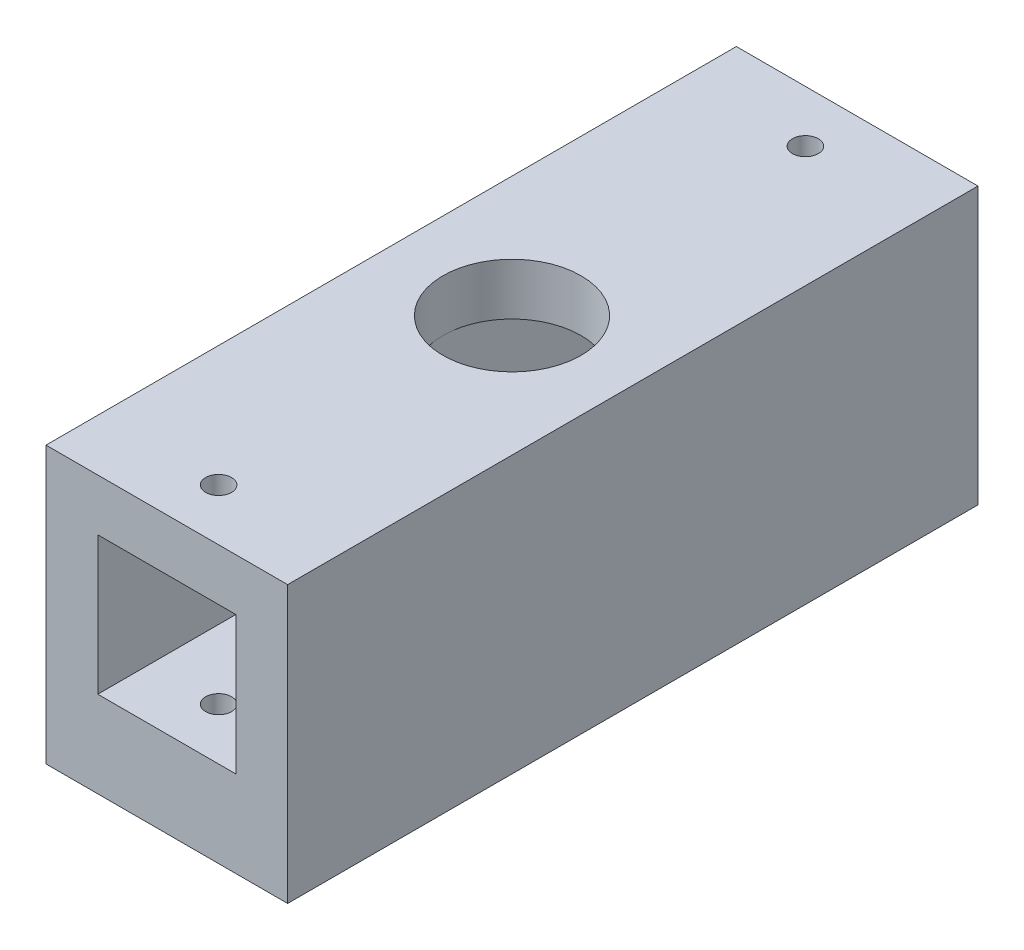
from build123d import *

# Parameters (mm, degrees)
SKETCH1_W               = 8
SKETCH1_H               = 8
BOSS_EXTRUDE1_DEPTH     = 40
SKETCH2_R               = 2.75
CUT_EXTRUDE1_DEPTH      = 18
SKETCH4_R               = 0.75
CUT_EXTRUDE2_DEPTH      = 19
CUT_EXTRUDE3_DEPTH      = 30
CUT_EXTRUDE3_DEPTH_BACK = 2
SKETCH2_5_R             = 4


with BuildPart() as part:
    # Sketch1 → Boss-Extrude1 (new body)
    with BuildSketch(Plane.XY):
        Polygon((-7, 7), (-7, -7), (-7, -9), (7, -9), (7, -7), (7, 7), align=None)
        Rectangle(SKETCH1_W, SKETCH1_H, mode=Mode.SUBTRACT)
    extrude(amount=BOSS_EXTRUDE1_DEPTH)

    # Sketch2 → Cut-Extrude1 (cut)
    with BuildSketch(Plane(origin=(0, -4, 0), x_dir=(1, 0, 0), z_dir=(0, 1, 0))):
        with Locations((0, -20)):
            Circle(SKETCH2_R)
    extrude(amount=-CUT_EXTRUDE1_DEPTH, mode=Mode.SUBTRACT)

    # Sketch4 → Cut-Extrude2 (cut)
    with BuildSketch(Plane(origin=(0, 7, 0), x_dir=(1, 0, 0), z_dir=(0, 1, 0))):
        with Locations((0, -3)):
            Circle(SKETCH4_R)
        with Locations((0, -37)):
            Circle(SKETCH4_R)
    extrude(amount=-CUT_EXTRUDE2_DEPTH, mode=Mode.SUBTRACT)

    # Sketch2_5 → Cut-Extrude3 (cut, two sides: drawn at the far end of the back side and taken through both)
    with BuildSketch(Plane(origin=(0, -4, 0), x_dir=(1, 0, 0), z_dir=(0, 1, 0)).offset(-CUT_EXTRUDE3_DEPTH_BACK)):
        with Locations((0, -20)):
            Circle(SKETCH2_5_R)
    extrude(amount=CUT_EXTRUDE3_DEPTH + CUT_EXTRUDE3_DEPTH_BACK, mode=Mode.SUBTRACT)


solid = part.part
